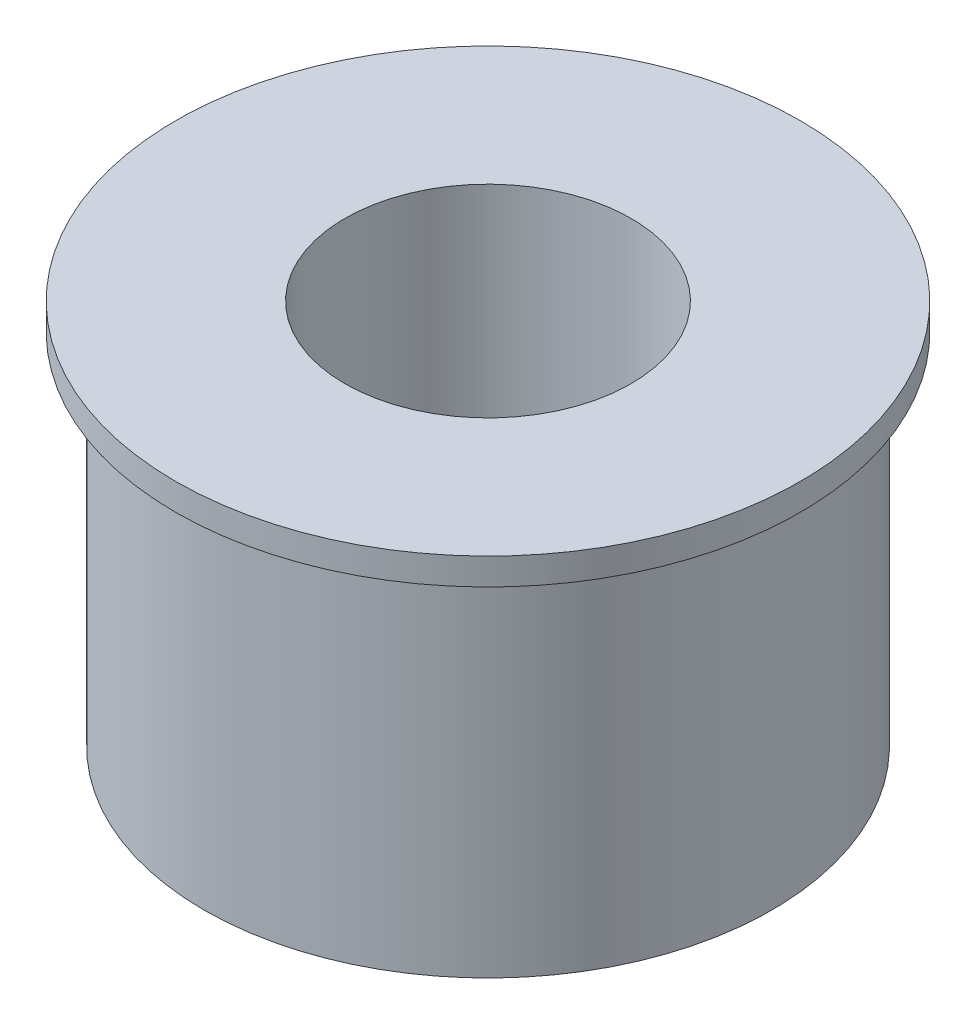
from build123d import *

# Parameters (mm, degrees)
SKETCH1_R           = 7.95
SKETCH1_R_2         = 4.01
BOSS_EXTRUDE1_DEPTH = 10.8
SKETCH2_R           = 8.75
SKETCH2_R_2         = 5.01
BOSS_EXTRUDE2_DEPTH = 0.75


with BuildPart() as part:
    # Sketch1 → Boss-Extrude1 (new body)
    with BuildSketch(Plane(origin=(0, 0, 0), x_dir=(1, 0, 0), z_dir=(0, 1, 0))):
        Circle(SKETCH1_R)
        Circle(SKETCH1_R_2, mode=Mode.SUBTRACT)
    extrude(amount=BOSS_EXTRUDE1_DEPTH)

    # Sketch2 → Boss-Extrude2 (add)
    with BuildSketch(Plane(origin=(0, 10.8, 0), x_dir=(-1, 0, 0), z_dir=(0, 1, 0))):
        Circle(SKETCH2_R)
        Circle(SKETCH2_R_2, mode=Mode.SUBTRACT)
    extrude(amount=-BOSS_EXTRUDE2_DEPTH)


solid = part.part
